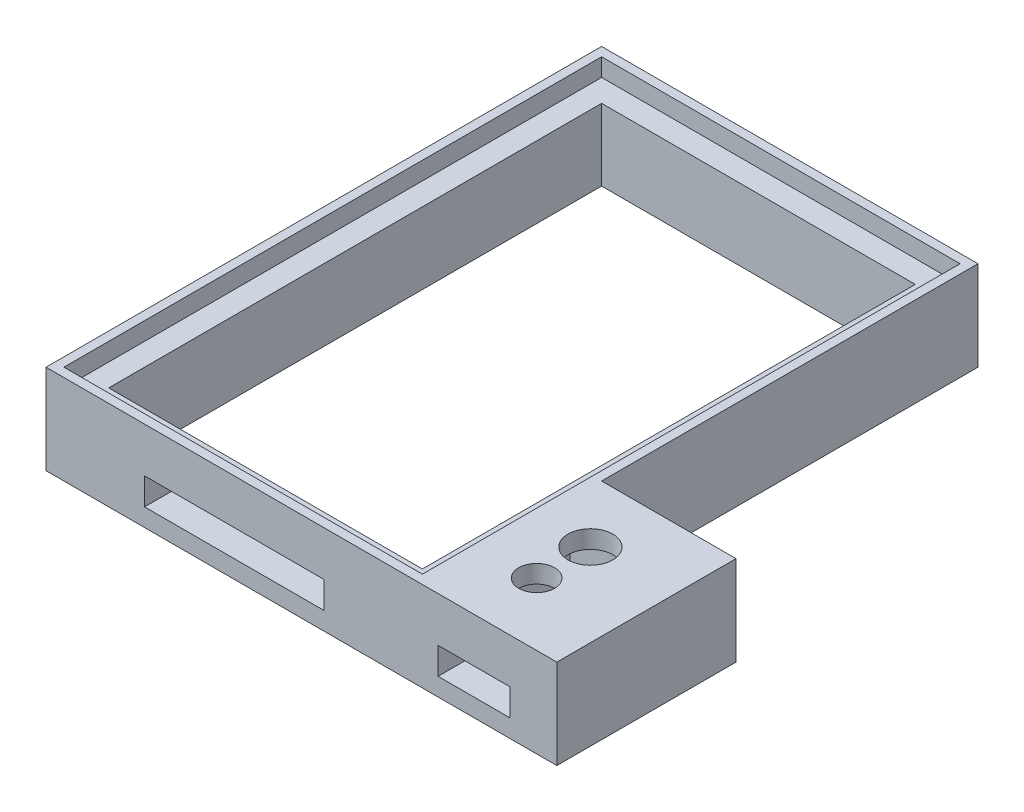
from build123d import *

# Parameters (mm, degrees)
CROQUIS1_W              = 42
CROQUIS1_H              = 62
SALIENTE_EXTRUIR1_DEPTH = 10
CROQUIS2_W              = 40
CROQUIS2_H              = 60
CORTAR_EXTRUIR1_DEPTH   = 2
CROQUIS3_W              = 35
CROQUIS3_H              = 55
CORTAR_EXTRUIR2_DEPTH   = 8
CROQUIS4_W              = 20
CROQUIS4_H              = 3
CORTAR_EXTRUIR3_DEPTH   = 8
CROQUIS5_W              = 20
CROQUIS5_H              = 10
SALIENTE_EXTRUIR2_DEPTH = 15
CROQUIS6_W              = 11.5
CROQUIS6_H              = 13
CORTAR_EXTRUIR4_DEPTH   = 8
CROQUIS7_R              = 2.5
CROQUIS7_R_2            = 2
CORTAR_EXTRUIR5_DEPTH   = 8
CROQUIS8_W              = 8
CROQUIS8_H              = 3
CORTAR_EXTRUIR6_DEPTH   = 8


with BuildPart() as part:
    # Croquis1 → Saliente-Extruir1 (new body)
    with BuildSketch(Plane(origin=(0, 0, 0), x_dir=(1, 0, 0), z_dir=(0, 1, 0))):
        Rectangle(CROQUIS1_W, CROQUIS1_H)
    extrude(amount=SALIENTE_EXTRUIR1_DEPTH)

    # Croquis2 → Cortar-Extruir1 (cut)
    with BuildSketch(Plane(origin=(0, 10, 0), x_dir=(1, 0, 0), z_dir=(0, 1, 0))):
        Rectangle(CROQUIS2_W, CROQUIS2_H)
    extrude(amount=-CORTAR_EXTRUIR1_DEPTH, mode=Mode.SUBTRACT)

    # Croquis3 → Cortar-Extruir2 (cut)
    with BuildSketch(Plane(origin=(0, 8, 0), x_dir=(1, 0, 0), z_dir=(0, 1, 0))):
        Rectangle(CROQUIS3_W, CROQUIS3_H)
    extrude(amount=-CORTAR_EXTRUIR2_DEPTH, mode=Mode.SUBTRACT)

    # Croquis4 → Cortar-Extruir3 (cut)
    with BuildSketch(Plane.XY.offset(31)):
        with Locations((0, 3.5)):
            Rectangle(CROQUIS4_W, CROQUIS4_H)
    extrude(amount=-CORTAR_EXTRUIR3_DEPTH, mode=Mode.SUBTRACT)

    # Croquis5 → Saliente-Extruir2 (add)
    with BuildSketch(Plane(origin=(21, 0, 0), x_dir=(0, 0, -1), z_dir=(1, 0, 0))):
        with Locations((-21, 5)):
            Rectangle(CROQUIS5_W, CROQUIS5_H)
    extrude(amount=SALIENTE_EXTRUIR2_DEPTH)

    # Croquis6 → Cortar-Extruir4 (cut)
    with BuildSketch(Plane(origin=(0, 0, 0), x_dir=(-1, 0, 0), z_dir=(0, -1, 0))):
        with Locations((-26.75, -21)):
            Rectangle(CROQUIS6_W, CROQUIS6_H)
    extrude(amount=-CORTAR_EXTRUIR4_DEPTH, mode=Mode.SUBTRACT)

    # Croquis7 → Cortar-Extruir5 (cut)
    with BuildSketch(Plane(origin=(0, 10, 0), x_dir=(1, 0, 0), z_dir=(0, 1, 0))):
        with Locations((26.75, -18)):
            Circle(CROQUIS7_R)
        with Locations((26.75, -24)):
            Circle(CROQUIS7_R_2)
    extrude(amount=-CORTAR_EXTRUIR5_DEPTH, mode=Mode.SUBTRACT)

    # Croquis8 → Cortar-Extruir6 (cut)
    with BuildSketch(Plane.XY.offset(31)):
        with Locations((26.75, 3.5)):
            Rectangle(CROQUIS8_W, CROQUIS8_H)
    extrude(amount=-CORTAR_EXTRUIR6_DEPTH, mode=Mode.SUBTRACT)


solid = part.part
